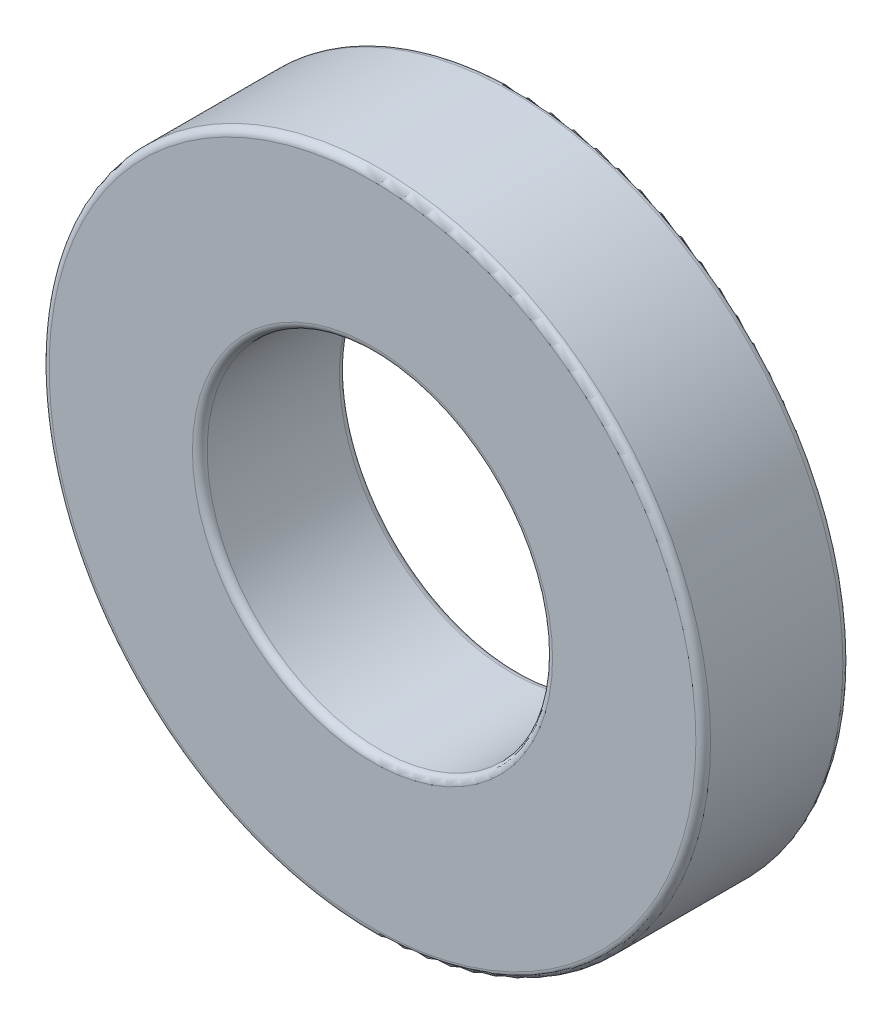
from build123d import *

# Parameters (mm, degrees)
SKETCH_1_R      = 4.5
SKETCH_1_R_2    = 2.35
EXTRUDE_1_DEPTH = 2
FILLET_1_R      = 0.1


with BuildPart() as part:
    # 草图1 → 凸台-拉伸1 (new body)
    with BuildSketch(Plane.XY):
        Circle(SKETCH_1_R)
        Circle(SKETCH_1_R_2, mode=Mode.SUBTRACT)
    extrude(amount=EXTRUDE_1_DEPTH)

    # 圆角1
    fillet_1_edges = [part.edges().sort_by_distance(p)[0] for p in [
        (-4.5, 0, 0),
        (-4.5, 0, 2),
        (-2.35, 0, 0),
        (-2.35, 0, 2),
    ]]
    fillet(fillet_1_edges, radius=FILLET_1_R)


solid = part.part
